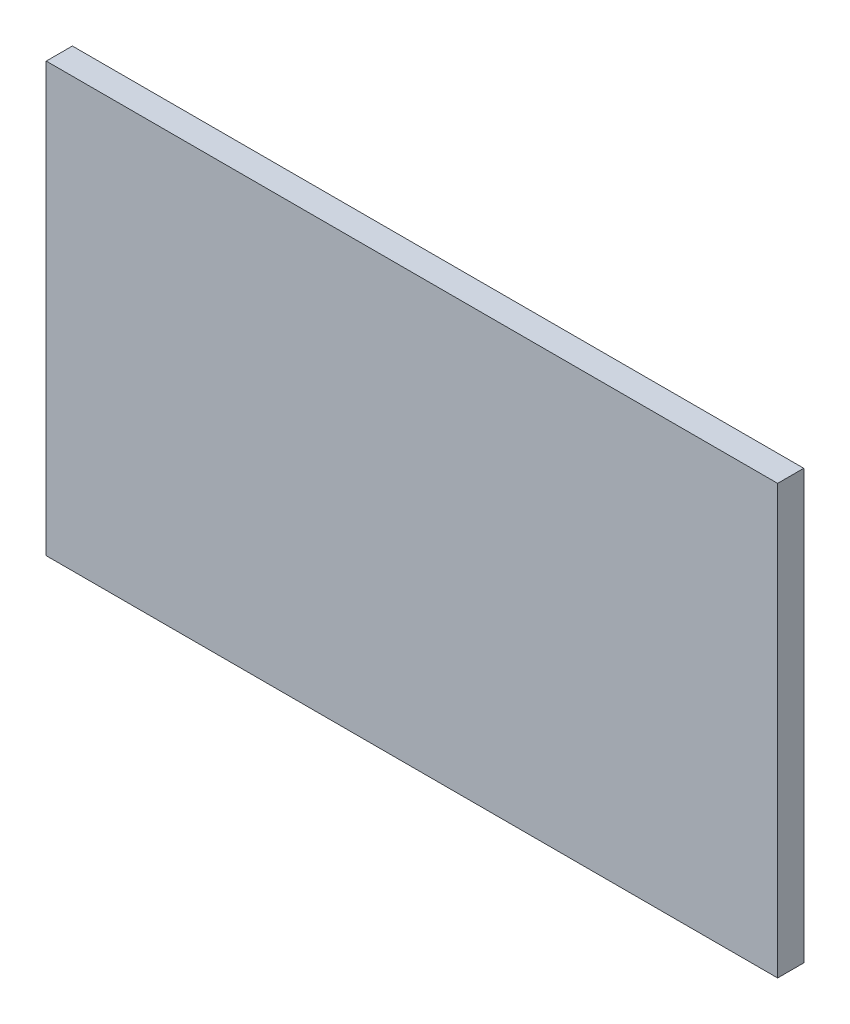
from build123d import *

# Parameters (mm, degrees)
SKETCH1_W           = 88.9
SKETCH1_H           = 52.07
BOSS_EXTRUDE1_DEPTH = 3.175


with BuildPart() as part:
    # Sketch1 → Boss-Extrude1 (new body)
    with BuildSketch(Plane.XY):
        with Locations((44.45, 26.035)):
            Rectangle(SKETCH1_W, SKETCH1_H)
    extrude(amount=BOSS_EXTRUDE1_DEPTH)


solid = part.part
